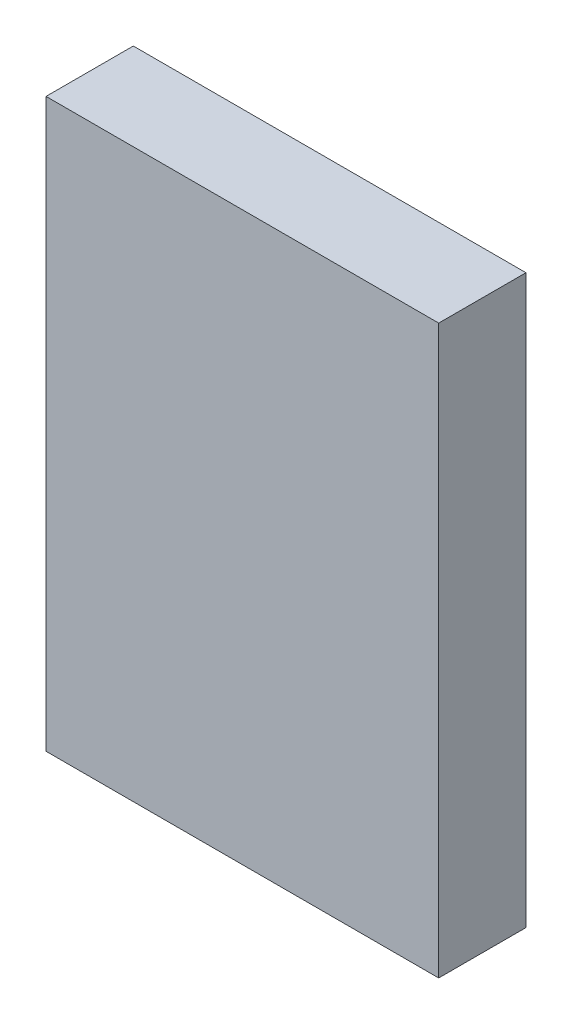
from build123d import *

# Parameters (mm, degrees)
ESQUISSE1_W        = 4.5
ESQUISSE1_H        = 6.5
BOSS_EXTRU_1_DEPTH = 1


with BuildPart() as part:
    # Esquisse1 → Boss.-Extru.1 (new body)
    with BuildSketch(Plane.XY):
        Rectangle(ESQUISSE1_W, ESQUISSE1_H)
    extrude(amount=BOSS_EXTRU_1_DEPTH)


solid = part.part
